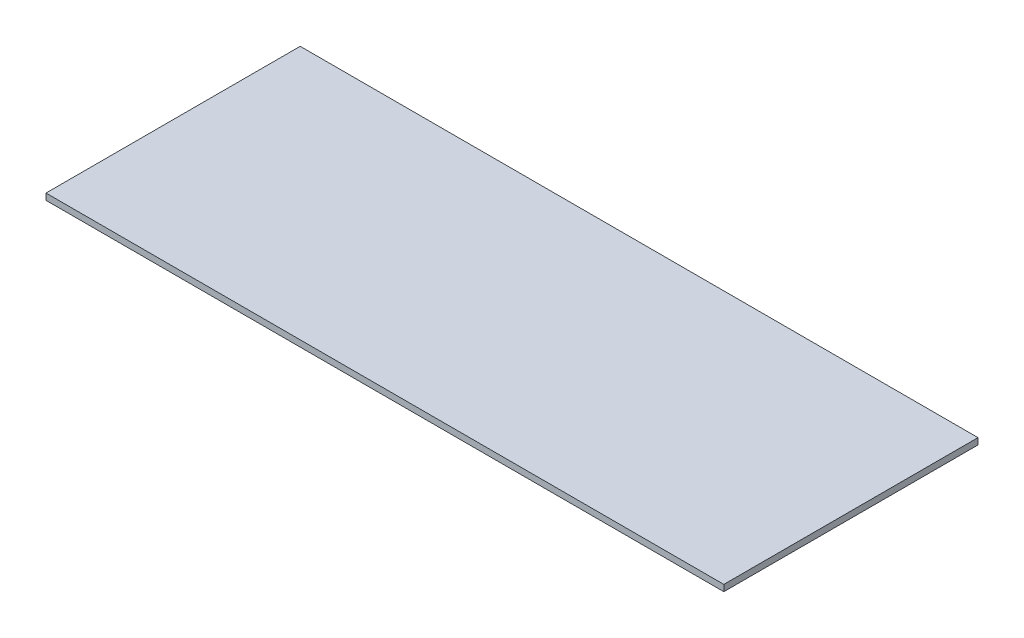
from build123d import *

# Parameters (mm, degrees)
SKETCH_1_W      = 160
SKETCH_1_H      = 60
EXTRUDE_1_DEPTH = 1.5


with BuildPart() as part:
    # Эскиз1 → Бобышка-Вытянуть1 (new body)
    with BuildSketch(Plane(origin=(0, 0, 0), x_dir=(1, 0, 0), z_dir=(0, 1, 0))):
        Rectangle(SKETCH_1_W, SKETCH_1_H)
    extrude(amount=EXTRUDE_1_DEPTH)


solid = part.part
